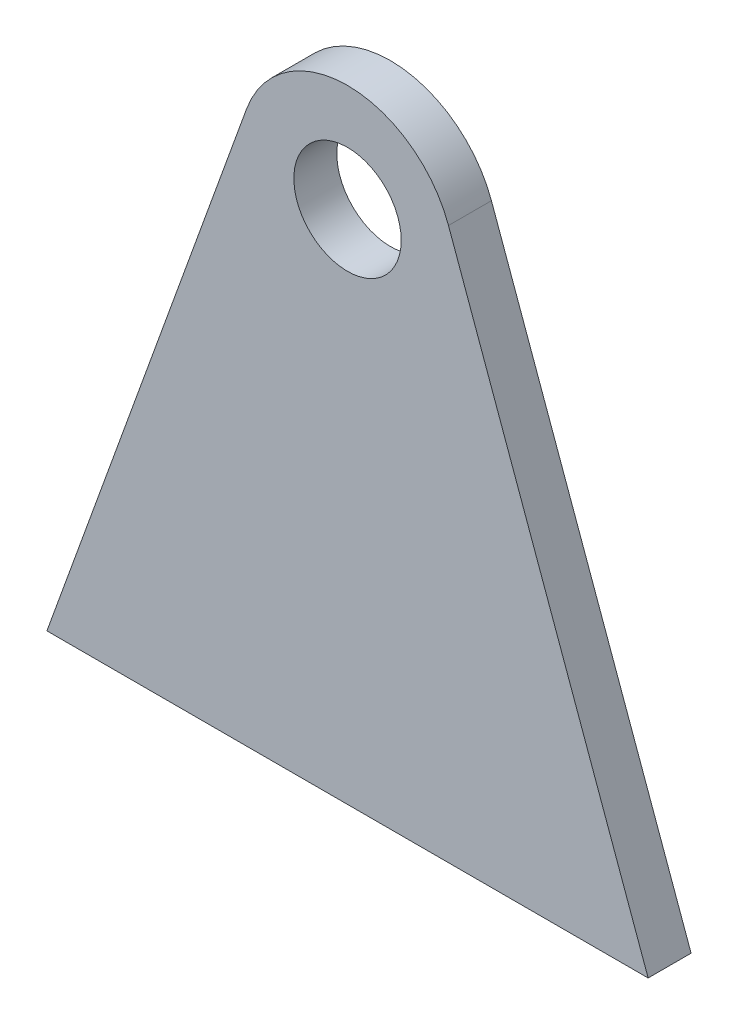
from build123d import *

# Parameters (mm, degrees)
SKETCH1_R           = 25
BOSS_EXTRUDE1_DEPTH = 20


with BuildPart() as part:
    # Sketch1 → Boss-Extrude1 (new body)
    with BuildSketch(Plane.XY):
        with BuildLine():
            Line((0, 0), (280, 0))
            Line((280, 0), (187.017565913, 257.010246783))
            ThreePointArc((187.017565913, 257.010246783), (140, 290), (92.982434087, 257.010246783))
            Line((92.982434087, 257.010246783), (0, 0))
        make_face()
        with Locations((140, 240)):
            Circle(SKETCH1_R, mode=Mode.SUBTRACT)
    extrude(amount=BOSS_EXTRUDE1_DEPTH)


solid = part.part
